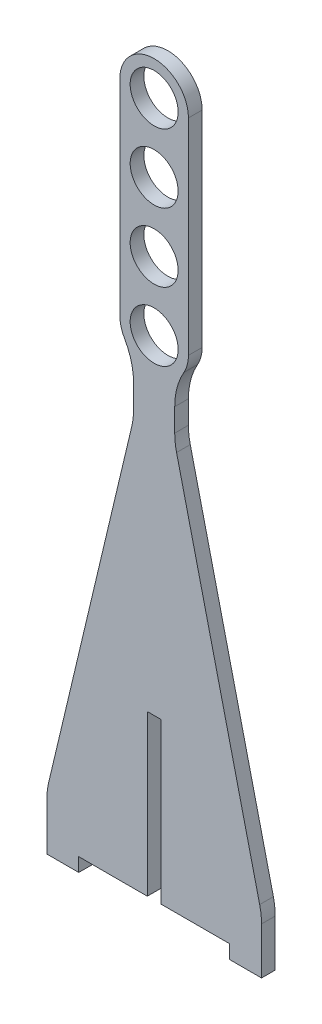
from build123d import *

# Parameters (mm, degrees)
ESBO_O1_R                = 5.25
RESSALTO_EXTRUS_O1_DEPTH = 3
FILETE1_R                = 15
ESBO_O2_W                = 3
ESBO_O2_H                = 35
CORTE_EXTRUS_O1_DEPTH    = 3


with BuildPart() as part:
    # Esboço1 → Ressalto-extrusão1 (new body)
    with BuildSketch(Plane.XY):
        with BuildLine():
            Line((-23.5, 0), (-16.5, 0))
            Line((-16.5, 0), (-16.5, 3))
            Line((-16.5, 3), (16.5, 3))
            Line((16.5, 3), (16.5, 0))
            Line((16.5, 0), (23.5, 0))
            Line((23.5, 0), (23.5, 12))
            Line((23.5, 12), (4.5, 92))
            Line((4.5, 92), (4.5, 104))
            ThreePointArc((4.5, 104), (6.708203932, 106.645898034), (7.5, 110))
            Line((7.5, 110), (7.5, 155))
            ThreePointArc((7.5, 155), (0, 162.5), (-7.5, 155))
            Line((-7.5, 155), (-7.5, 110))
            ThreePointArc((-7.5, 110), (-6.708203932, 106.645898034), (-4.5, 104))
            Line((-4.5, 104), (-4.5, 92))
            Line((-4.5, 92), (-23.5, 12))
            Line((-23.5, 12), (-23.5, 0))
        make_face()
        with Locations((0, 110)):
            Circle(ESBO_O1_R, mode=Mode.SUBTRACT)
        with Locations((0, 125)):
            Circle(ESBO_O1_R, mode=Mode.SUBTRACT)
        with Locations((0, 140)):
            Circle(ESBO_O1_R, mode=Mode.SUBTRACT)
        with Locations((0, 155)):
            Circle(ESBO_O1_R, mode=Mode.SUBTRACT)
    extrude(amount=RESSALTO_EXTRUS_O1_DEPTH)

    # Filete1
    filete1_edges = [part.edges().sort_by_distance(p)[0] for p in [
        (-23.5, 12, 1.5),
        (-4.5, 92, 1.5),
        (-4.5, 104, 1.5),
        (4.5, 104, 1.5),
        (4.5, 92, 1.5),
        (23.5, 12, 1.5),
    ]]
    fillet(filete1_edges, radius=FILETE1_R)

    # Esboço2 → Corte-extrusão1 (cut)
    with BuildSketch(Plane.XY.offset(3)):
        with Locations((0, 20.5)):
            Rectangle(ESBO_O2_W, ESBO_O2_H)
    extrude(amount=-CORTE_EXTRUS_O1_DEPTH, mode=Mode.SUBTRACT)


solid = part.part
